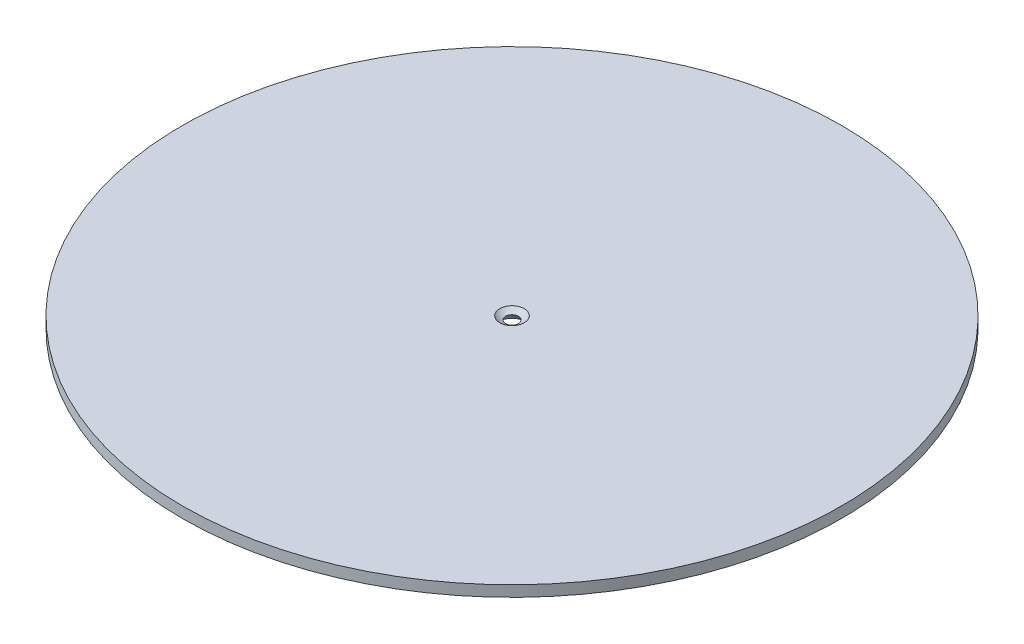
from build123d import *

# Parameters (mm, degrees)
SKETCH1_R           = 1150.00024
BOSS_EXTRUDE1_DEPTH = 38.1


with BuildPart() as part:
    # Sketch1 → Boss-Extrude1 (new body)
    with BuildSketch(Plane(origin=(0, 0, 0), x_dir=(1, 0, 0), z_dir=(0, 1, 0))):
        Circle(SKETCH1_R)
    extrude(amount=BOSS_EXTRUDE1_DEPTH)

    # Sketch2 → Cut-Revolve1 (revolve, cut)
    with BuildSketch(Plane.XY):
        with BuildLine():
            Line((0, 0), (0, 38.1))
            Line((0, 38.1), (42.704112888, 38.1))
            ThreePointArc((42.704112888, 38.1), (33.057419264, 30.815191944), (22.281337432, 25.337675478))
            ThreePointArc((22.281337432, 25.337675478), (34.122583246, 13.982542532), (42.704112888, 0))
            Line((42.704112888, 0), (0, 0))
        make_face()
    revolve(axis=Axis((0, 0, 0), (0, 1, 0)), mode=Mode.SUBTRACT)


solid = part.part
